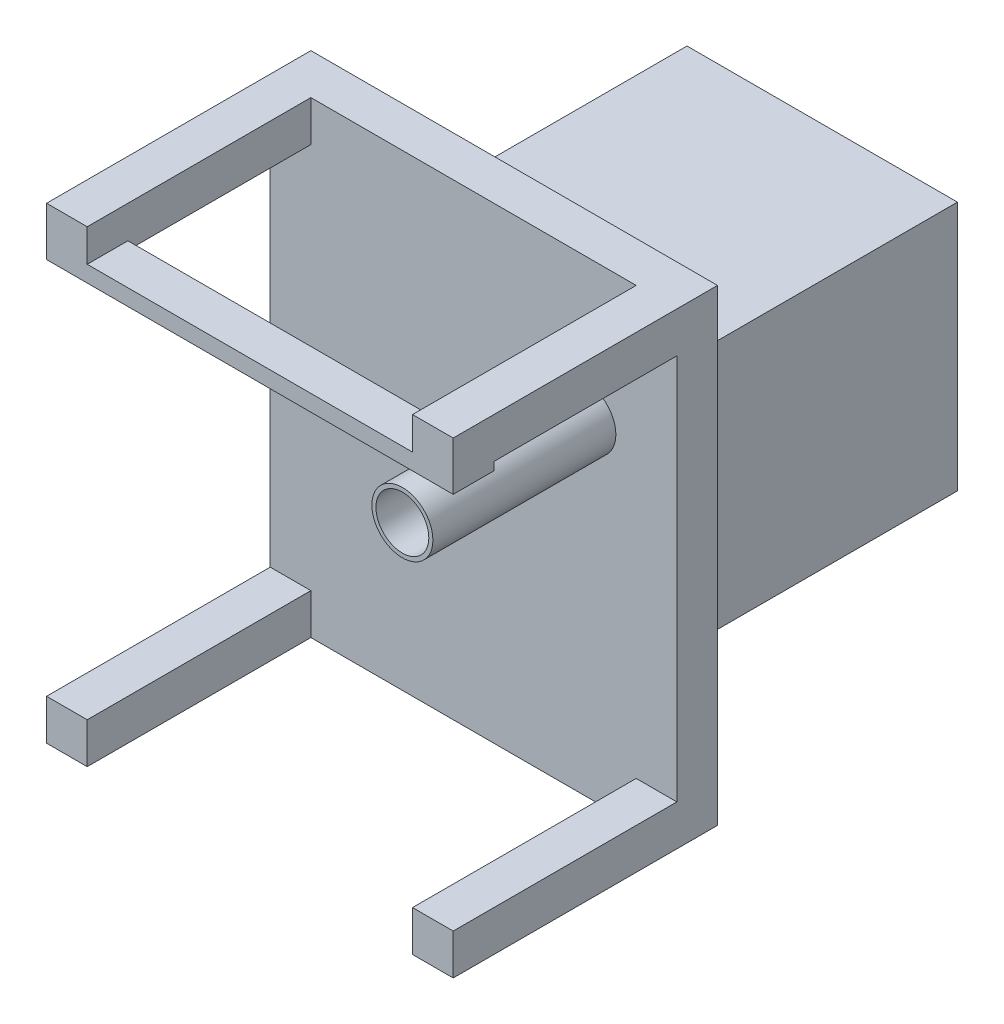
from build123d import *

# Parameters (mm, degrees)
ESQUISSE1_W             = 100
ESQUISSE1_H             = 115
BOSS_EXTRU_2_DEPTH      = 10
ESQUISSE2_W             = 10
ESQUISSE2_H             = 10
BOSS_EXTRU_8_DEPTH      = 55
ESQUISSE9_W             = 10
ESQUISSE9_H             = 10
BOSS_EXTRU_9_DEPTH      = 55
ESQUISSE10_W            = 10
ESQUISSE10_H            = 10
BOSS_EXTRU_10_DEPTH     = 55
ESQUISSE11_W            = 10
ESQUISSE11_H            = 10
BOSS_EXTRU_11_DEPTH     = 55
ESQUISSE14_W            = 100
ESQUISSE14_H            = 10
BOSS_EXTRU_12_DEPTH     = 2
ESQUISSE15_W            = 80
ESQUISSE15_H            = 10
BOSS_EXTRU_13_DEPTH     = 2
ESQUISSE16_R            = 7.5
BOSS_EXTRU_16_DEPTH     = 45
ESQUISSE17_R            = 6.5
ENL_V_MAT_EXTRU_1_DEPTH = 59
ESQUISSE18_W            = 5
ESQUISSE18_H            = 56.5
BOSS_EXTRU_17_DEPTH     = 70
ESQUISSE19_W            = 56.5
ESQUISSE19_H            = 5
BOSS_EXTRU_18_DEPTH     = 70
ESQUISSE21_W            = 5
ESQUISSE21_H            = 56.5
BOSS_EXTRU_19_DEPTH     = 70
ESQUISSE22_W            = 66.5
ESQUISSE22_H            = 5
BOSS_EXTRU_20_DEPTH     = 70
BOSS_EXTRU_21_DEPTH     = 70
ENL_V_MAT_EXTRU_2_DEPTH = 70
BOSS_EXTRU_26_REACH     = 89.238
BOSS_EXTRU_28_REACH     = 86


with BuildPart() as part:
    # Esquisse1 → Boss.-Extru.2 (new body)
    with BuildSketch(Plane.XY):
        with Locations((50, 57.5)):
            Rectangle(ESQUISSE1_W, ESQUISSE1_H)
    extrude(amount=BOSS_EXTRU_2_DEPTH)

    # Esquisse2 → Boss.-Extru.8 (add)
    with BuildSketch(Plane.XY.offset(10)):
        with Locations((5, 110)):
            Rectangle(ESQUISSE2_W, ESQUISSE2_H)
    extrude(amount=BOSS_EXTRU_8_DEPTH)

    # Esquisse9 → Boss.-Extru.9 (add)
    with BuildSketch(Plane.XY.offset(10)):
        with Locations((95, 110)):
            Rectangle(ESQUISSE9_W, ESQUISSE9_H)
    extrude(amount=BOSS_EXTRU_9_DEPTH)

    # Esquisse10 → Boss.-Extru.10 (add)
    with BuildSketch(Plane.XY.offset(10)):
        with Locations((5, 5)):
            Rectangle(ESQUISSE10_W, ESQUISSE10_H)
    extrude(amount=BOSS_EXTRU_10_DEPTH)

    # Esquisse11 → Boss.-Extru.11 (add)
    with BuildSketch(Plane.XY.offset(10)):
        with Locations((95, 5)):
            Rectangle(ESQUISSE11_W, ESQUISSE11_H)
    extrude(amount=BOSS_EXTRU_11_DEPTH)

    # Esquisse14 → Boss.-Extru.12 (add)
    with BuildSketch(Plane.XZ.offset(-105)):
        with Locations((50, 60)):
            Rectangle(ESQUISSE14_W, ESQUISSE14_H)
    extrude(amount=BOSS_EXTRU_12_DEPTH)

    # Esquisse15 → Boss.-Extru.13 (add)
    with BuildSketch(Plane(origin=(0, 105, 0), x_dir=(1, 0, 0), z_dir=(0, 1, 0))):
        with Locations((50, -60)):
            Rectangle(ESQUISSE15_W, ESQUISSE15_H)
    extrude(amount=BOSS_EXTRU_13_DEPTH)

    # Esquisse16 → Boss.-Extru.16 (add)
    with BuildSketch(Plane.XY.offset(10)):
        with Locations((77.5, 80.738453234)):
            Circle(ESQUISSE16_R)
    extrude(amount=BOSS_EXTRU_16_DEPTH)

    # Esquisse17 → Enlèv. mat.-Extru.1 (cut)
    with BuildSketch(Plane.XY.offset(55)):
        with Locations((77.5, 80.738453234)):
            Circle(ESQUISSE17_R)
    extrude(amount=-ENL_V_MAT_EXTRU_1_DEPTH, mode=Mode.SUBTRACT)

    # Esquisse18 → Boss.-Extru.17 (add)
    with BuildSketch(Plane(origin=(0, 0, 0), x_dir=(-1, 0, 0), z_dir=(0, 0, -1))):
        with Locations((-25, 58.988453234)):
            Rectangle(ESQUISSE18_W, ESQUISSE18_H)
    extrude(amount=BOSS_EXTRU_17_DEPTH)

    # Esquisse19 → Boss.-Extru.18 (add)
    with BuildSketch(Plane(origin=(0, 0, 0), x_dir=(-1, 0, 0), z_dir=(0, 0, -1))):
        with Locations((-55.75, 33.238453234)):
            Rectangle(ESQUISSE19_W, ESQUISSE19_H)
    extrude(amount=BOSS_EXTRU_18_DEPTH)

    # Esquisse21 → Boss.-Extru.19 (add)
    with BuildSketch(Plane(origin=(0, 0, 0), x_dir=(-1, 0, 0), z_dir=(0, 0, -1))):
        with Locations((-86.5, 58.988453234)):
            Rectangle(ESQUISSE21_W, ESQUISSE21_H)
    extrude(amount=BOSS_EXTRU_19_DEPTH)

    # Esquisse22 → Boss.-Extru.20 (add)
    with BuildSketch(Plane(origin=(0, 0, 0), x_dir=(-1, 0, 0), z_dir=(0, 0, -1))):
        with Locations((-55.75, 89.738453234)):
            Rectangle(ESQUISSE22_W, ESQUISSE22_H)
    extrude(amount=BOSS_EXTRU_20_DEPTH)

    # Esquisse26 → Boss.-Extru.21 (add)
    with BuildSketch(Plane(origin=(0, 0, -70), x_dir=(-1, 0, 0), z_dir=(0, 0, -1))):
        Polygon((-27.5, 87.238453234), (-84, 35.738453234), (-27.5, 35.738453234), align=None)
    extrude(amount=-BOSS_EXTRU_21_DEPTH)

    # Esquisse23 → Enlèv. mat.-Extru.2 (cut)
    with BuildSketch(Plane(origin=(0, 0, -70), x_dir=(-1, 0, 0), z_dir=(0, 0, -1))):
        Polygon((-27.5, 87.238453234), (-84, 35.738453234), (-27.5, 35.738453234), align=None)
    extrude(amount=-ENL_V_MAT_EXTRU_2_DEPTH, mode=Mode.SUBTRACT)

    # Esquisse24 → Boss.-Extru.26 (add, up to next)
    with BuildSketch(Plane.XZ.offset(-87.238453234), mode=Mode.PRIVATE) as boss_extru_26_sk1:
        Polygon((27.5, -50), (71.5, 0), (27.5, 0), align=None)
    boss_extru_26_tool1 = extrude(boss_extru_26_sk1.sketch, amount=BOSS_EXTRU_26_REACH, mode=Mode.PRIVATE) - part.part
    add(boss_extru_26_tool1.solids().sort_by_distance((42.166667, 87.238453, -16.666667))[0])

    # Esquisse29 → Boss.-Extru.28 (add, up to next)
    with BuildSketch(Plane.ZY.offset(-84), mode=Mode.PRIVATE) as boss_extru_28_sk1:
        Polygon((0, 35.738453234), (-50, 35.738453234), (0, 74.738453234), align=None)
    boss_extru_28_tool1 = extrude(boss_extru_28_sk1.sketch, amount=BOSS_EXTRU_28_REACH, mode=Mode.PRIVATE) - part.part
    add(boss_extru_28_tool1.solids().sort_by_distance((84, 48.738453, -16.666667))[0])


solid = part.part
